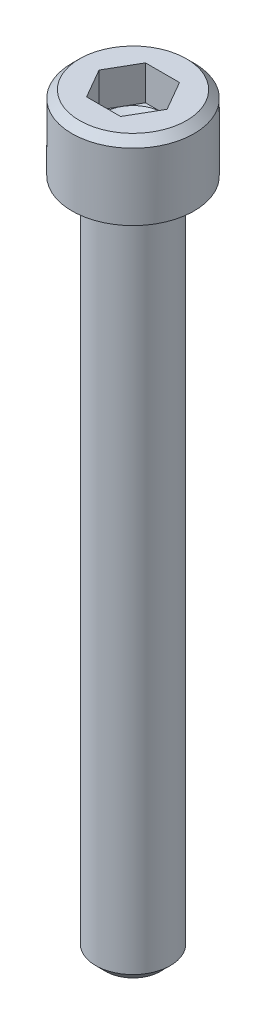
from build123d import *

# Parameters (mm, degrees)
SKETCH1_W           = 2.8702
SKETCH1_H           = 3.5052
SKETCH2_R           = 1.7526
BOSS_EXTRUDE1_DEPTH = 31.75
CUT_EXTRUDE1_DEPTH  = 1.6256
CHAMFER1_SIZE       = 0.47244
CHAMFER2_SIZE       = 0.3556
FILLET1_R           = 0.254


with BuildPart() as part:
    # Sketch1 → Revolve1 (revolve)
    with BuildSketch(Plane.XY):
        with Locations((1.4351, 1.7526)):
            Rectangle(SKETCH1_W, SKETCH1_H)
    revolve(axis=Axis((0, 3.5052, 0), (0, -1, 0)))

    # Sketch2 → Boss-Extrude1 (add)
    with BuildSketch(Plane.XZ):
        Circle(SKETCH2_R)
    extrude(amount=BOSS_EXTRUDE1_DEPTH)

    # Sketch3 → Cut-Extrude1 (cut)
    with BuildSketch(Plane(origin=(0, 3.5052, 0), x_dir=(-1, 0, 0), z_dir=(0, 1, 0))):
        Polygon((-0.799225978, 1.3843), (-1.598451955, 0), (-0.799225978, -1.3843), (0.799225978, -1.3843), (1.598451955, 0), (0.799225978, 1.3843), align=None)
    extrude(amount=-CUT_EXTRUDE1_DEPTH, mode=Mode.SUBTRACT)

    # Sketch4 → Cut-Revolve1 (revolve, cut)
    with BuildSketch(Plane.XY):
        Polygon((1.3843, 1.8796), (0, 1.8796), (0, 1.080374022), align=None)
    revolve(axis=Axis((0, 1.879625, 0), (0, -1, 0)), mode=Mode.SUBTRACT)

    # Chamfer1
    chamfer1_edges = [part.edges().sort_by_distance(p)[0] for p in [
        (-1.7526, -31.75, 0),
    ]]
    chamfer(chamfer1_edges, length=CHAMFER1_SIZE)

    # Chamfer2
    chamfer2_edges = [part.edges().sort_by_distance(p)[0] for p in [
        (-2.8702, 3.5052, 0),
    ]]
    chamfer(chamfer2_edges, length=CHAMFER2_SIZE)

    # Fillet1
    fillet1_edges = [part.edges().sort_by_distance(p)[0] for p in [
        (-1.7526, 0, 0),
    ]]
    fillet(fillet1_edges, radius=FILLET1_R)


solid = part.part
